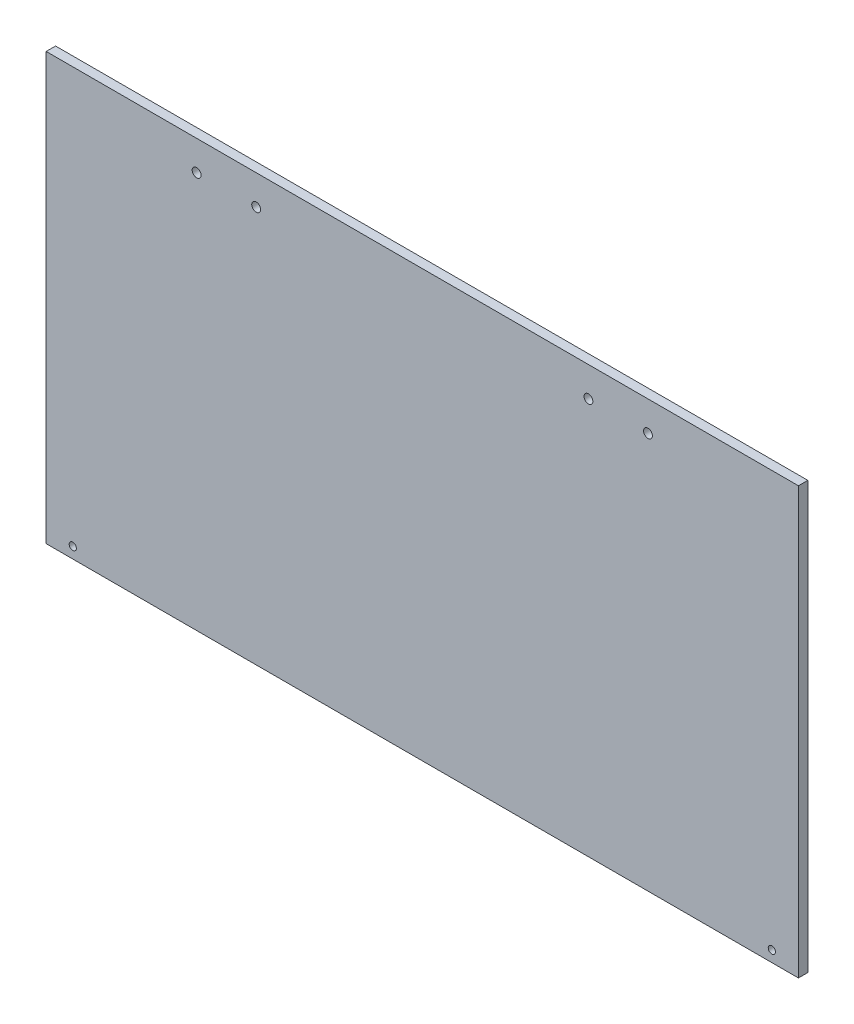
from build123d import *

# Parameters (mm, degrees)
SKETCH1_W                 = 381
SKETCH1_H                 = 215.9
BOSS_EXTRUDE1_DEPTH       = 4.7625
F_8_CLEARANCE_HOLE1_D     = 4.4958
F_8_CLEARANCE_HOLE1_DEPTH = 74.422
F_8_CLEARANCE_HOLE1_TIP   = 1.350674586
F_6_CLEARANCE_HOLE1_D     = 3.6576
F_6_CLEARANCE_HOLE1_DEPTH = 74.422
F_6_CLEARANCE_HOLE1_TIP   = 1.0988539


with BuildPart() as part:
    # Sketch1 → Boss-Extrude1 (new body)
    with BuildSketch(Plane.XY):
        Rectangle(SKETCH1_W, SKETCH1_H)
    extrude(amount=BOSS_EXTRUDE1_DEPTH)

    # #8 Clearance Hole1
    with Locations(Plane.XY.offset(4.7625)):
        with Locations((-114.3, 92.86875), (-84.1375, 92.86875), (84.1375, 92.86875), (114.3, 92.86875)):
            Hole(F_8_CLEARANCE_HOLE1_D / 2, depth=F_8_CLEARANCE_HOLE1_DEPTH)
            with Locations((0, 0, -(F_8_CLEARANCE_HOLE1_DEPTH + F_8_CLEARANCE_HOLE1_TIP / 2))):  # 118° drill point
                Cone(0, F_8_CLEARANCE_HOLE1_D / 2, F_8_CLEARANCE_HOLE1_TIP, mode=Mode.SUBTRACT)

    # #6 Clearance Hole1
    with Locations(Plane.XY.offset(4.7625)):
        with Locations((-177.02911, -102.362), (177.02911, -102.362)):
            Hole(F_6_CLEARANCE_HOLE1_D / 2, depth=F_6_CLEARANCE_HOLE1_DEPTH)
            with Locations((0, 0, -(F_6_CLEARANCE_HOLE1_DEPTH + F_6_CLEARANCE_HOLE1_TIP / 2))):  # 118° drill point
                Cone(0, F_6_CLEARANCE_HOLE1_D / 2, F_6_CLEARANCE_HOLE1_TIP, mode=Mode.SUBTRACT)


solid = part.part
